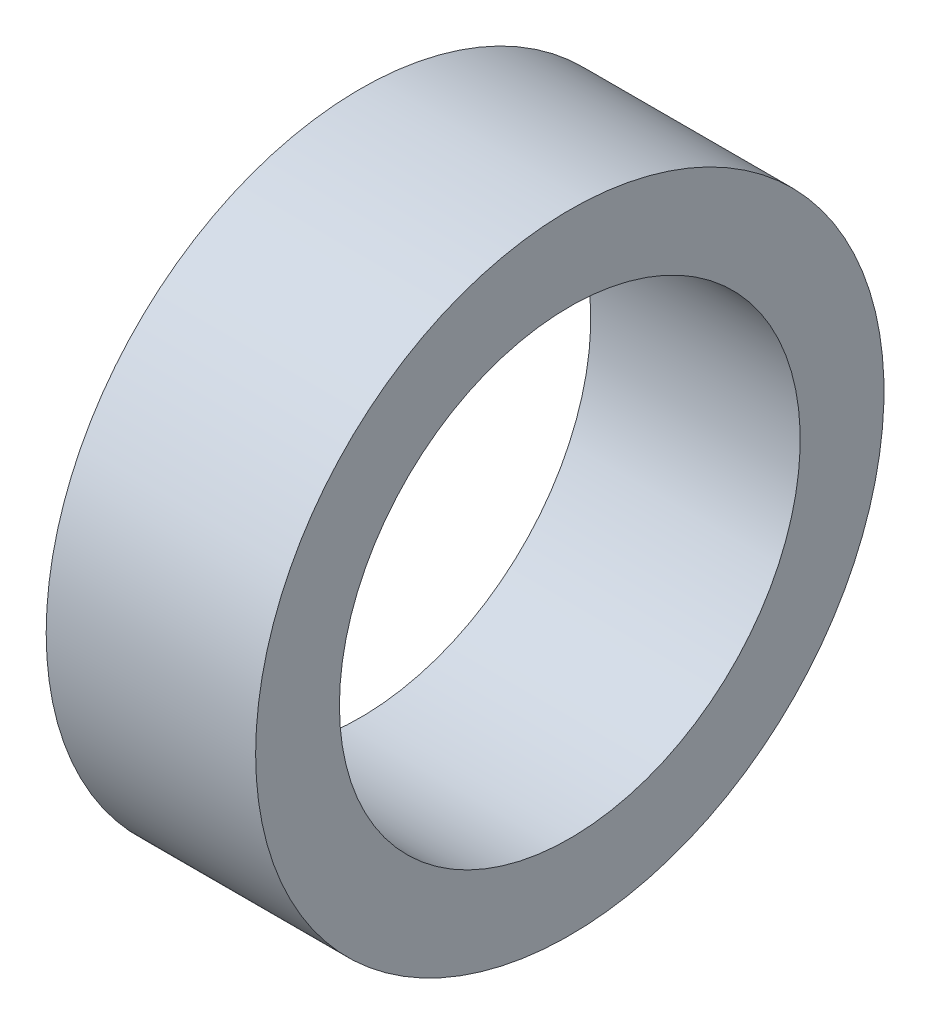
from build123d import *

# Parameters (mm, degrees)
SKETCH2_W = 25.4
SKETCH2_H = 10.16


with BuildPart() as part:
    # Sketch2 → Revolve1 (revolve)
    with BuildSketch(Plane(origin=(0, 0, 0), x_dir=(1, 0, 0), z_dir=(0, 1, 0))):
        with Locations((0, 33.02)):
            Rectangle(SKETCH2_W, SKETCH2_H)
    revolve(axis=Axis((-13.97, 0, 0), (1, 0, 0)))


solid = part.part
